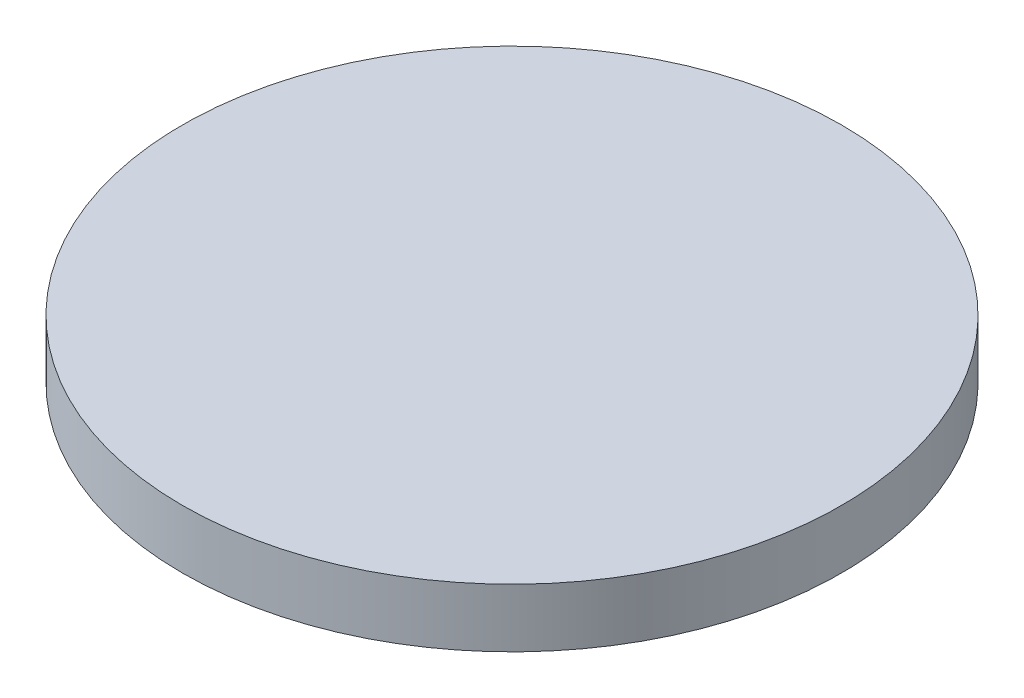
from build123d import *

# Parameters (mm, degrees)
CROQUIS1_R              = 22.5
SALIENTE_EXTRUIR1_DEPTH = 4


with BuildPart() as part:
    # Croquis1 → Saliente-Extruir1 (new body)
    with BuildSketch(Plane(origin=(0, 0, 0), x_dir=(1, 0, 0), z_dir=(0, 1, 0))):
        Circle(CROQUIS1_R)
    extrude(amount=SALIENTE_EXTRUIR1_DEPTH)


solid = part.part
